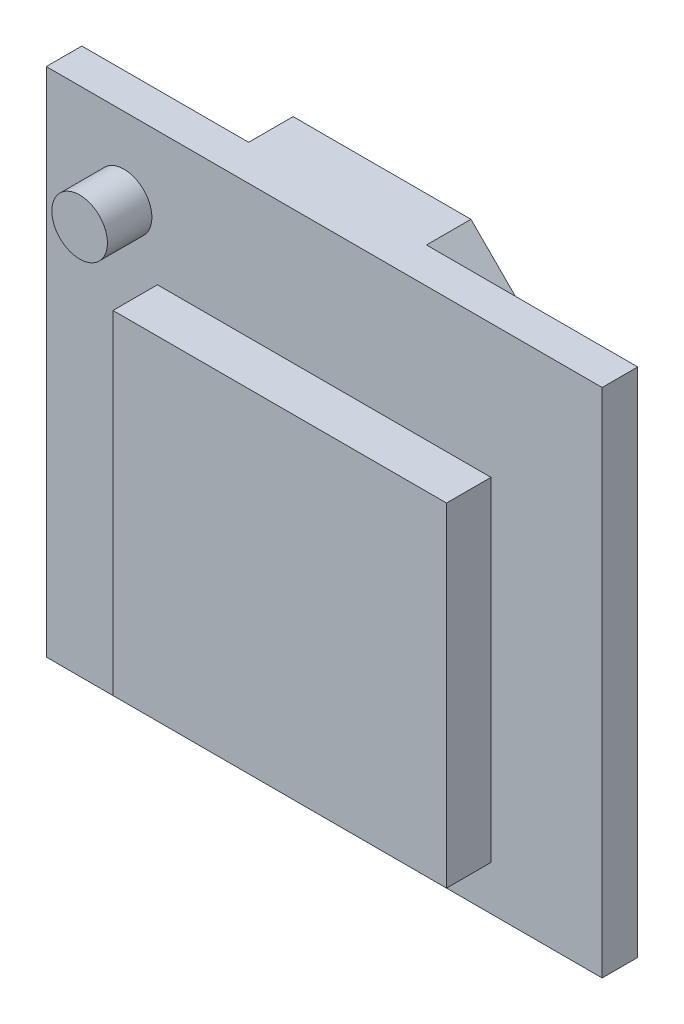
from build123d import *

# Parameters (mm, degrees)
SKETCH_1_W      = 25
SKETCH_1_H      = 23
EXTRUDE_1_DEPTH = 1.6
SKETCH_2_R      = 1.25
SKETCH_2_W      = 15
SKETCH_2_H      = 15
EXTRUDE_2_DEPTH = 2
EXTRUDE_3_DEPTH = 2


with BuildPart() as part:
    # Эскиз1 → Бобышка-Вытянуть1 (new body)
    with BuildSketch(Plane.XY):
        with Locations((12.5, 11.5)):
            Rectangle(SKETCH_1_W, SKETCH_1_H)
    extrude(amount=EXTRUDE_1_DEPTH)

    # Эскиз2 → Бобышка-Вытянуть2 (add)
    with BuildSketch(Plane.XY.offset(1.6)):
        with Locations((3.5, 19.5)):
            Circle(SKETCH_2_R)
        with Locations((12.5, 9.5)):
            Rectangle(SKETCH_2_W, SKETCH_2_H)
    extrude(amount=EXTRUDE_2_DEPTH)

    # Эскиз3 → Бобышка-Вытянуть3 (add)
    with BuildSketch(Plane(origin=(0, 0, 0), x_dir=(-1, 0, 0), z_dir=(0, 0, -1))):
        Polygon((-15.5, 23), (-7.5, 23), (-7.5, 7), (-17.5, 7), (-17.5, 21), align=None)
    extrude(amount=EXTRUDE_3_DEPTH)


solid = part.part
